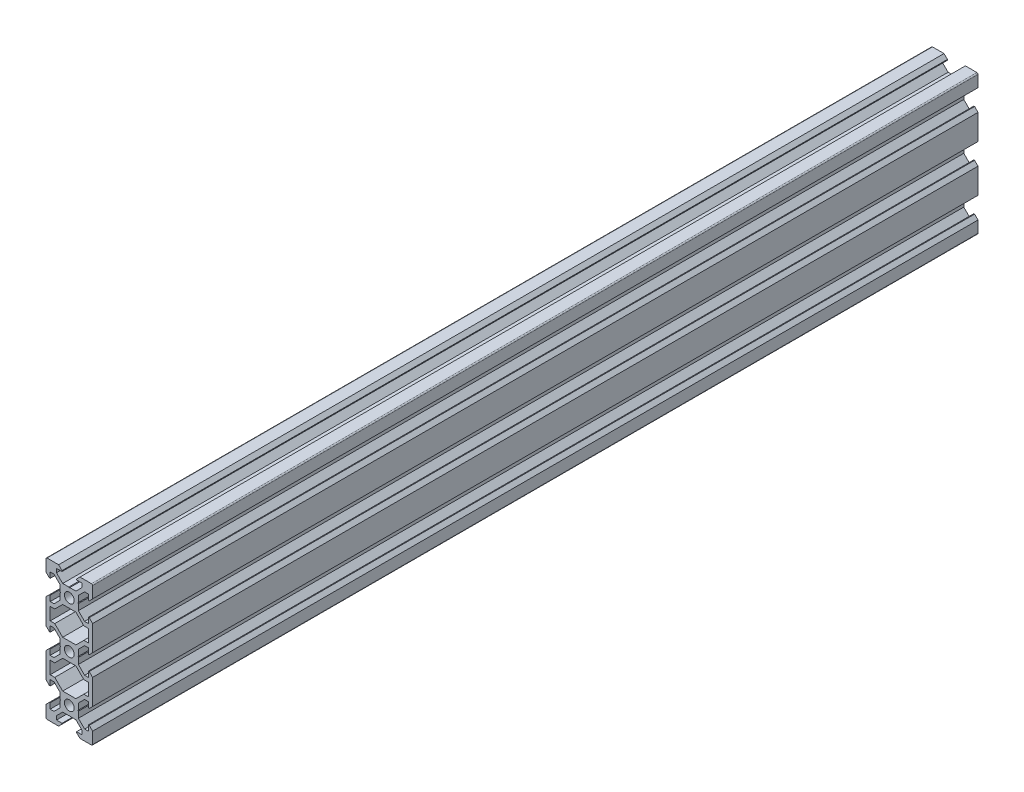
from build123d import *

# Parameters (mm, degrees)
SKETCH1_R           = 2.1
BOSS_EXTRUDE1_DEPTH = 380


with BuildPart() as part:
    # Sketch1 → Boss-Extrude1 (new body)
    with BuildSketch(Plane.XY):
        with BuildLine():
            Line((4.58, -30), (9.5, -30))
            ThreePointArc((9.5, -30), (9.853553391, -29.853553391), (10, -29.5))
            Line((10, -29.5), (10, -24.58))
            Line((10, -24.58), (8.545, -23.125))
            Line((8.545, -23.125), (8.2, -23.125))
            Line((8.2, -23.125), (8.2, -25.5))
            Line((8.2, -25.5), (6.560660172, -25.5))
            Line((6.560660172, -25.5), (3.9, -22.839339828))
            Line((3.9, -22.839339828), (3.9, -20.21))
            Line((3.9, -20.21), (3.69, -20))
            Line((3.69, -20), (3.9, -19.79))
            Line((3.9, -19.79), (3.9, -17.160660172))
            Line((3.9, -17.160660172), (6.560660172, -14.5))
            Line((6.560660172, -14.5), (8.2, -14.5))
            Line((8.2, -14.5), (8.2, -16.875))
            Line((8.2, -16.875), (8.545, -16.875))
            Line((8.545, -16.875), (10, -15.42))
            Line((10, -15.42), (10, -4.58))
            Line((10, -4.58), (8.545, -3.125))
            Line((8.545, -3.125), (8.2, -3.125))
            Line((8.2, -3.125), (8.2, -5.5))
            Line((8.2, -5.5), (6.560660172, -5.5))
            Line((6.560660172, -5.5), (3.9, -2.839339828))
            Line((3.9, -2.839339828), (3.9, -0.21))
            Line((3.9, -0.21), (3.69, 0))
            Line((3.69, 0), (3.9, 0.21))
            Line((3.9, 0.21), (3.9, 2.839339828))
            Line((3.9, 2.839339828), (6.560660172, 5.5))
            Line((6.560660172, 5.5), (8.2, 5.5))
            Line((8.2, 5.5), (8.2, 3.125))
            Line((8.2, 3.125), (8.545, 3.125))
            Line((8.545, 3.125), (10, 4.58))
            Line((10, 4.58), (10, 15.42))
            Line((10, 15.42), (8.545, 16.875))
            Line((8.545, 16.875), (8.2, 16.875))
            Line((8.2, 16.875), (8.2, 14.5))
            Line((8.2, 14.5), (6.560660172, 14.5))
            Line((6.560660172, 14.5), (3.9, 17.160660172))
            Line((3.9, 17.160660172), (3.9, 19.79))
            Line((3.9, 19.79), (3.69, 20))
            Line((3.69, 20), (3.9, 20.21))
            Line((3.9, 20.21), (3.9, 22.839339828))
            Line((3.9, 22.839339828), (6.560660172, 25.5))
            Line((6.560660172, 25.5), (8.2, 25.5))
            Line((8.2, 25.5), (8.2, 23.125))
            Line((8.2, 23.125), (8.545, 23.125))
            Line((8.545, 23.125), (10, 24.58))
            Line((10, 24.58), (10, 29.5))
            ThreePointArc((10, 29.5), (9.853553391, 29.853553391), (9.5, 30))
            Line((9.5, 30), (4.58, 30))
            Line((4.58, 30), (3.125, 28.545))
            Line((3.125, 28.545), (3.125, 28.2))
            Line((3.125, 28.2), (5.5, 28.2))
            Line((5.5, 28.2), (5.5, 26.560660172))
            Line((5.5, 26.560660172), (2.839339828, 23.9))
            Line((2.839339828, 23.9), (0.21, 23.9))
            Line((0.21, 23.9), (0, 23.69))
            Line((0, 23.69), (-0.21, 23.9))
            Line((-0.21, 23.9), (-2.839339828, 23.9))
            Line((-2.839339828, 23.9), (-5.5, 26.560660172))
            Line((-5.5, 26.560660172), (-5.5, 28.2))
            Line((-5.5, 28.2), (-3.125, 28.2))
            Line((-3.125, 28.2), (-3.125, 28.545))
            Line((-3.125, 28.545), (-4.58, 30))
            Line((-4.58, 30), (-9.5, 30))
            ThreePointArc((-9.5, 30), (-9.853553391, 29.853553391), (-10, 29.5))
            Line((-10, 29.5), (-10, 24.58))
            Line((-10, 24.58), (-8.545, 23.125))
            Line((-8.545, 23.125), (-8.2, 23.125))
            Line((-8.2, 23.125), (-8.2, 25.5))
            Line((-8.2, 25.5), (-6.560660172, 25.5))
            Line((-6.560660172, 25.5), (-3.9, 22.839339828))
            Line((-3.9, 22.839339828), (-3.9, 20.21))
            Line((-3.9, 20.21), (-3.69, 20))
            Line((-3.69, 20), (-3.9, 19.79))
            Line((-3.9, 19.79), (-3.9, 17.160660172))
            Line((-3.9, 17.160660172), (-6.560660172, 14.5))
            Line((-6.560660172, 14.5), (-8.2, 14.5))
            Line((-8.2, 14.5), (-8.2, 16.875))
            Line((-8.2, 16.875), (-8.545, 16.875))
            Line((-8.545, 16.875), (-10, 15.42))
            Line((-10, 15.42), (-10, 4.58))
            Line((-10, 4.58), (-8.545, 3.125))
            Line((-8.545, 3.125), (-8.2, 3.125))
            Line((-8.2, 3.125), (-8.2, 5.5))
            Line((-8.2, 5.5), (-6.560660172, 5.5))
            Line((-6.560660172, 5.5), (-3.9, 2.839339828))
            Line((-3.9, 2.839339828), (-3.9, 0.21))
            Line((-3.9, 0.21), (-3.69, 0))
            Line((-3.69, 0), (-3.9, -0.21))
            Line((-3.9, -0.21), (-3.9, -2.839339828))
            Line((-3.9, -2.839339828), (-6.560660172, -5.5))
            Line((-6.560660172, -5.5), (-8.2, -5.5))
            Line((-8.2, -5.5), (-8.2, -3.125))
            Line((-8.2, -3.125), (-8.545, -3.125))
            Line((-8.545, -3.125), (-10, -4.58))
            Line((-10, -4.58), (-10, -15.42))
            Line((-10, -15.42), (-8.545, -16.875))
            Line((-8.545, -16.875), (-8.2, -16.875))
            Line((-8.2, -16.875), (-8.2, -14.5))
            Line((-8.2, -14.5), (-6.560660172, -14.5))
            Line((-6.560660172, -14.5), (-3.9, -17.160660172))
            Line((-3.9, -17.160660172), (-3.9, -19.79))
            Line((-3.9, -19.79), (-3.69, -20))
            Line((-3.69, -20), (-3.9, -20.21))
            Line((-3.9, -20.21), (-3.9, -22.839339828))
            Line((-3.9, -22.839339828), (-6.560660172, -25.5))
            Line((-6.560660172, -25.5), (-8.2, -25.5))
            Line((-8.2, -25.5), (-8.2, -23.125))
            Line((-8.2, -23.125), (-8.545, -23.125))
            Line((-8.545, -23.125), (-10, -24.58))
            Line((-10, -24.58), (-10, -29.5))
            ThreePointArc((-10, -29.5), (-9.853553391, -29.853553391), (-9.5, -30))
            Line((-9.5, -30), (-4.58, -30))
            Line((-4.58, -30), (-3.125, -28.545))
            Line((-3.125, -28.545), (-3.125, -28.2))
            Line((-3.125, -28.2), (-5.5, -28.2))
            Line((-5.5, -28.2), (-5.5, -26.560660172))
            Line((-5.5, -26.560660172), (-2.839339828, -23.9))
            Line((-2.839339828, -23.9), (-0.21, -23.9))
            Line((-0.21, -23.9), (0, -23.69))
            Line((0, -23.69), (0.21, -23.9))
            Line((0.21, -23.9), (2.839339828, -23.9))
            Line((2.839339828, -23.9), (5.5, -26.560660172))
            Line((5.5, -26.560660172), (5.5, -28.2))
            Line((5.5, -28.2), (3.125, -28.2))
            Line((3.125, -28.2), (3.125, -28.545))
            Line((3.125, -28.545), (4.58, -30))
        make_face()
        with Locations((0, -20)):
            Circle(SKETCH1_R, mode=Mode.SUBTRACT)
        Polygon((-6.239339828, -12.7), (-8.2, -12.7), (-8.2, -7.3), (-6.239339828, -7.3), (-2.839339828, -3.9), (2.839339828, -3.9), (6.239339828, -7.3), (8.2, -7.3), (8.2, -12.7), (6.239339828, -12.7), (2.839339828, -16.1), (-2.839339828, -16.1), align=None, mode=Mode.SUBTRACT)
        Polygon((-6.239339828, 7.3), (-8.2, 7.3), (-8.2, 12.7), (-6.239339828, 12.7), (-2.839339828, 16.1), (2.839339828, 16.1), (6.239339828, 12.7), (8.2, 12.7), (8.2, 7.3), (6.239339828, 7.3), (2.839339828, 3.9), (-2.839339828, 3.9), align=None, mode=Mode.SUBTRACT)
        with Locations((0, 20)):
            Circle(SKETCH1_R, mode=Mode.SUBTRACT)
        Circle(SKETCH1_R, mode=Mode.SUBTRACT)
    extrude(amount=BOSS_EXTRUDE1_DEPTH)


solid = part.part
